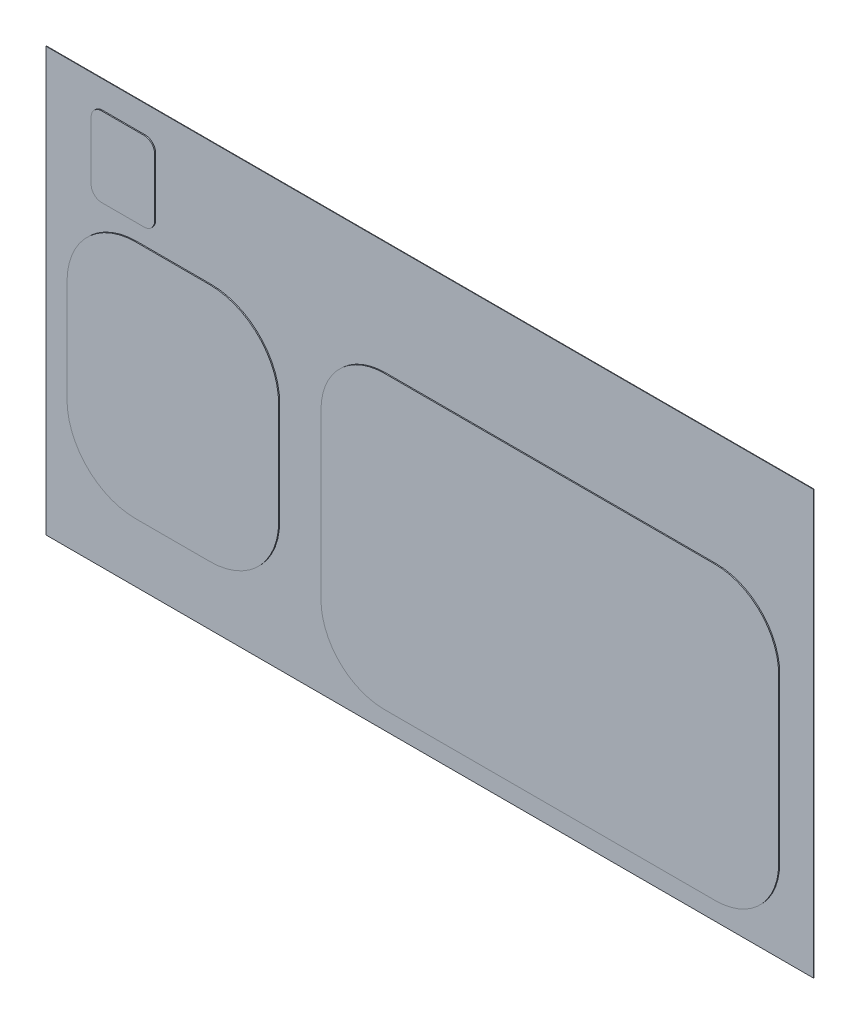
from build123d import *

# Parameters (mm, degrees)
SKETCH1_W          = 145000
SKETCH1_H          = 80000
EXTRUDE1_DEPTH     = 300
SKETCH2_OUTSIDE_W  = 178123.044
SKETCH2_OUTSIDE_H  = 113123.044
CUT_EXTRUDE1_DEPTH = 200


with BuildPart() as part:
    # Sketch1 → Extrude1 (new body)
    with BuildSketch(Plane.XY):
        with Locations((57500, 27500)):
            Rectangle(SKETCH1_W, SKETCH1_H)
    extrude(amount=-EXTRUDE1_DEPTH)

    # Sketch2 outside → Cut-Extrude1 (cut)
    with BuildSketch(Plane.XY):
        with Locations((57500, 27500)):
            Rectangle(SKETCH2_OUTSIDE_W, SKETCH2_OUTSIDE_H)
        with BuildLine():
            Line((37145.057737679, 34139.633625626), (37145.057737679, 3109.633625626))
            ThreePointArc((37145.057737679, 3109.633625626), (40659.77636344, -5375.647748613), (49145.057737679, -8890.366374374))
            Line((49145.057737679, -8890.366374374), (111645.057737679, -8890.366374374))
            ThreePointArc((111645.057737679, -8890.366374374), (120130.339111917, -5375.647748613), (123645.057737679, 3109.633625626))
            Line((123645.057737679, 3109.633625626), (123645.057737679, 34139.633625626))
            ThreePointArc((123645.057737679, 34139.633625626), (120130.339111917, 42624.914999864), (111645.057737679, 46139.633625626))
            Line((111645.057737679, 46139.633625626), (49145.057737679, 46139.633625626))
            ThreePointArc((49145.057737679, 46139.633625626), (40659.77636344, 42624.914999864), (37145.057737679, 34139.633625626))
        make_face(mode=Mode.SUBTRACT)
        with BuildLine():
            Line((16145.057737679, 44139.633625626), (2145.057737679, 44139.633625626))
            ThreePointArc((2145.057737679, 44139.633625626), (-7047.330417747, 40332.021781051), (-10854.942262321, 31139.633625626))
            Line((-10854.942262321, 31139.633625626), (-10854.942262321, 11839.633625626))
            ThreePointArc((-10854.942262321, 11839.633625626), (-7047.330417747, 2647.245470201), (2145.057737679, -1160.366374374))
            Line((2145.057737679, -1160.366374374), (16145.057737679, -1160.366374374))
            ThreePointArc((16145.057737679, -1160.366374374), (25337.445893104, 2647.245470201), (29145.057737679, 11839.633625626))
            Line((29145.057737679, 11839.633625626), (29145.057737679, 31139.633625626))
            ThreePointArc((29145.057737679, 31139.633625626), (25337.445893104, 40332.021781051), (16145.057737679, 44139.633625626))
        make_face(mode=Mode.SUBTRACT)
        with BuildLine():
            Line((-6301.000457401, 60369.727650707), (-6301.000457401, 49369.727650707))
            ThreePointArc((-6301.000457401, 49369.727650707), (-5715.214019774, 47955.514088334), (-4301.000457401, 47369.727650707))
            Line((-4301.000457401, 47369.727650707), (3698.999542599, 47369.727650707))
            ThreePointArc((3698.999542599, 47369.727650707), (5113.213104972, 47955.514088334), (5698.999542599, 49369.727650707))
            Line((5698.999542599, 49369.727650707), (5698.999542599, 60369.727650707))
            ThreePointArc((5698.999542599, 60369.727650707), (5113.213104972, 61783.941213081), (3698.999542599, 62369.727650707))
            Line((3698.999542599, 62369.727650707), (-4301.000457401, 62369.727650707))
            ThreePointArc((-4301.000457401, 62369.727650707), (-5715.214019774, 61783.941213081), (-6301.000457401, 60369.727650707))
        make_face(mode=Mode.SUBTRACT)
    extrude(amount=-CUT_EXTRUDE1_DEPTH, mode=Mode.SUBTRACT)


solid = part.part
